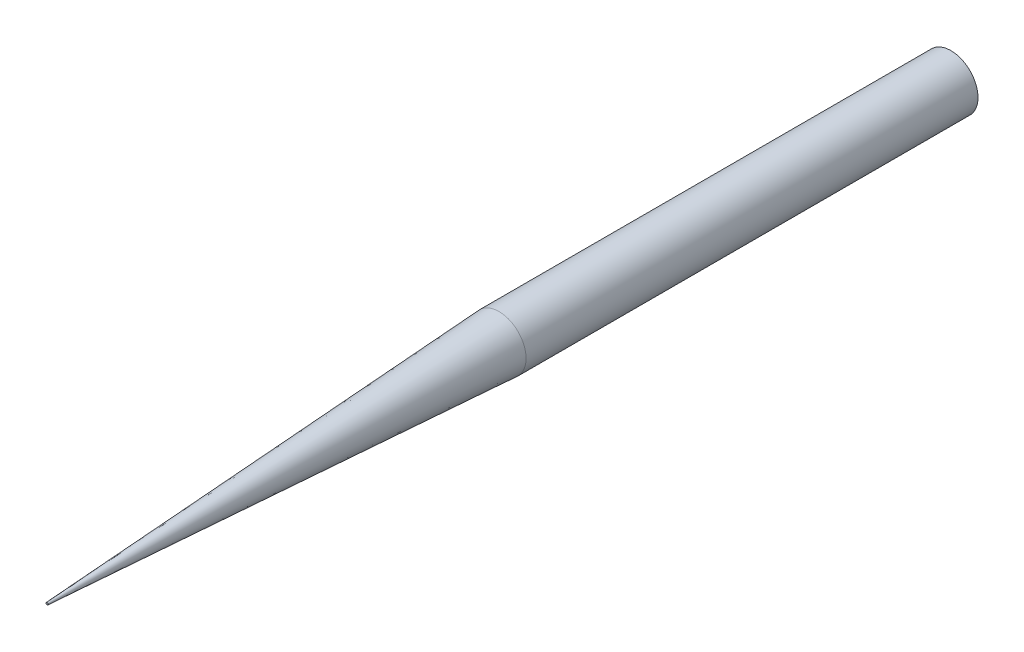
from build123d import *

# Parameters (mm, degrees)
SKETCH1_R      = 1.5
EXTRUDE1_DEPTH = 50
CHAMFER1_SIZE  = 25
CHAMFER1_SIZE2 = 1.44149093


with BuildPart() as part:
    # Sketch1 → Extrude1 (new body)
    with BuildSketch(Plane.XY):
        Circle(SKETCH1_R)
    extrude(amount=EXTRUDE1_DEPTH)

    # Chamfer1
    chamfer1_edges = [part.edges().sort_by_distance(p)[0] for p in [
        (-1.5, 0, 50),
    ]]
    chamfer1_side = [part.faces().sort_by_distance(p)[0] for p in [
        (-1.5, 0, 25),
    ]]
    chamfer(chamfer1_edges, length=CHAMFER1_SIZE, length2=CHAMFER1_SIZE2, reference=chamfer1_side[0])


solid = part.part
